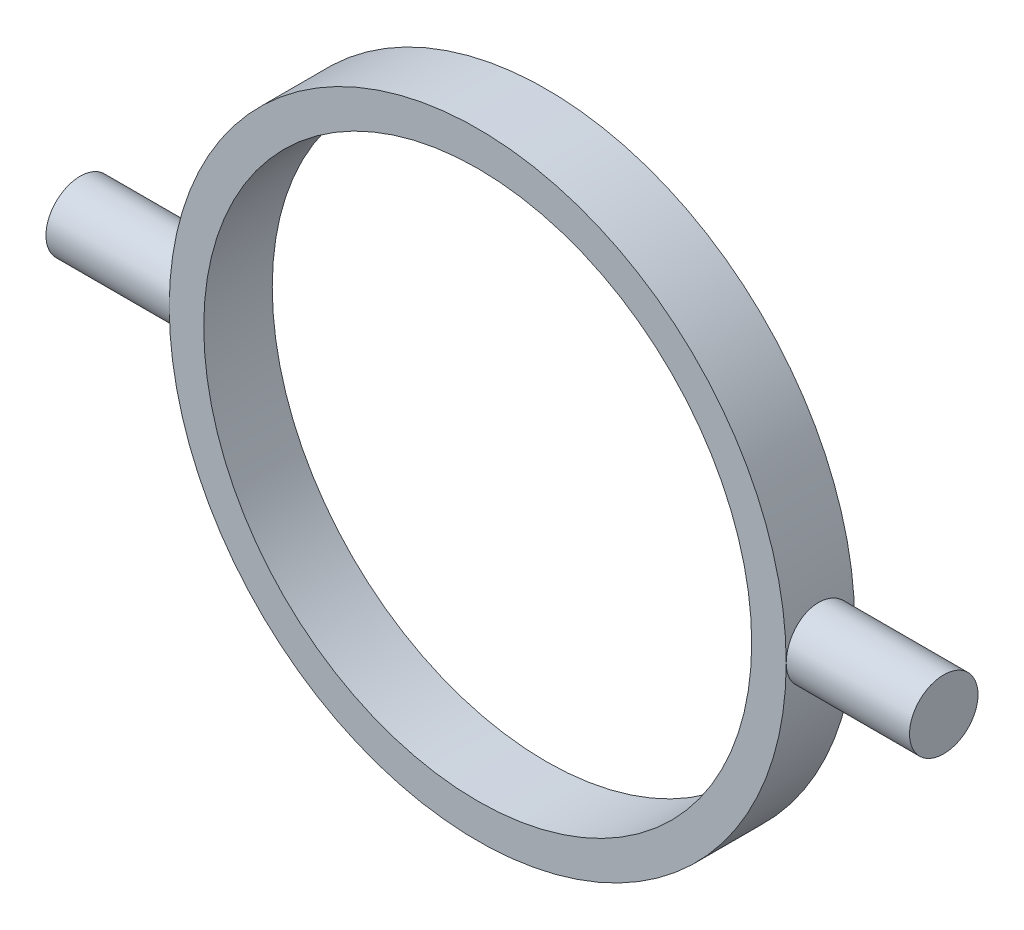
from build123d import *

# Parameters (mm, degrees)
SKETCH1_R           = 14.3
SKETCH1_R_2         = 12.7
BOSS_EXTRUDE1_DEPTH = 3.175
BOSS_EXTRUDE2_START = -0.635
SKETCH2_R           = 1.5875
BOSS_EXTRUDE2_DEPTH = 6.35
CIRPATTERN1_COUNT   = 2


with BuildPart() as part:
    # Sketch1 → Boss-Extrude1 (new body)
    with BuildSketch(Plane.XY):
        Circle(SKETCH1_R)
        Circle(SKETCH1_R_2, mode=Mode.SUBTRACT)
    extrude(amount=BOSS_EXTRUDE1_DEPTH)

    # Sketch2 → Boss-Extrude2 (add)
    with BuildSketch(Plane(origin=(14.3, 0, 0), x_dir=(0, 0, -1), z_dir=(1, 0, 0)).offset(BOSS_EXTRUDE2_START)):
        with Locations((-1.5875, 0)):
            Circle(SKETCH2_R)
    boss_extrude2 = extrude(amount=BOSS_EXTRUDE2_DEPTH)

    # CirPattern1: Boss-Extrude2 ×2 about axis
    cirpattern1_axis = Axis((0, 0, 3.175), (0, 0, -1))
    for i in range(1, CIRPATTERN1_COUNT):
        add(boss_extrude2.rotate(cirpattern1_axis, i * 360 / CIRPATTERN1_COUNT))


solid = part.part
